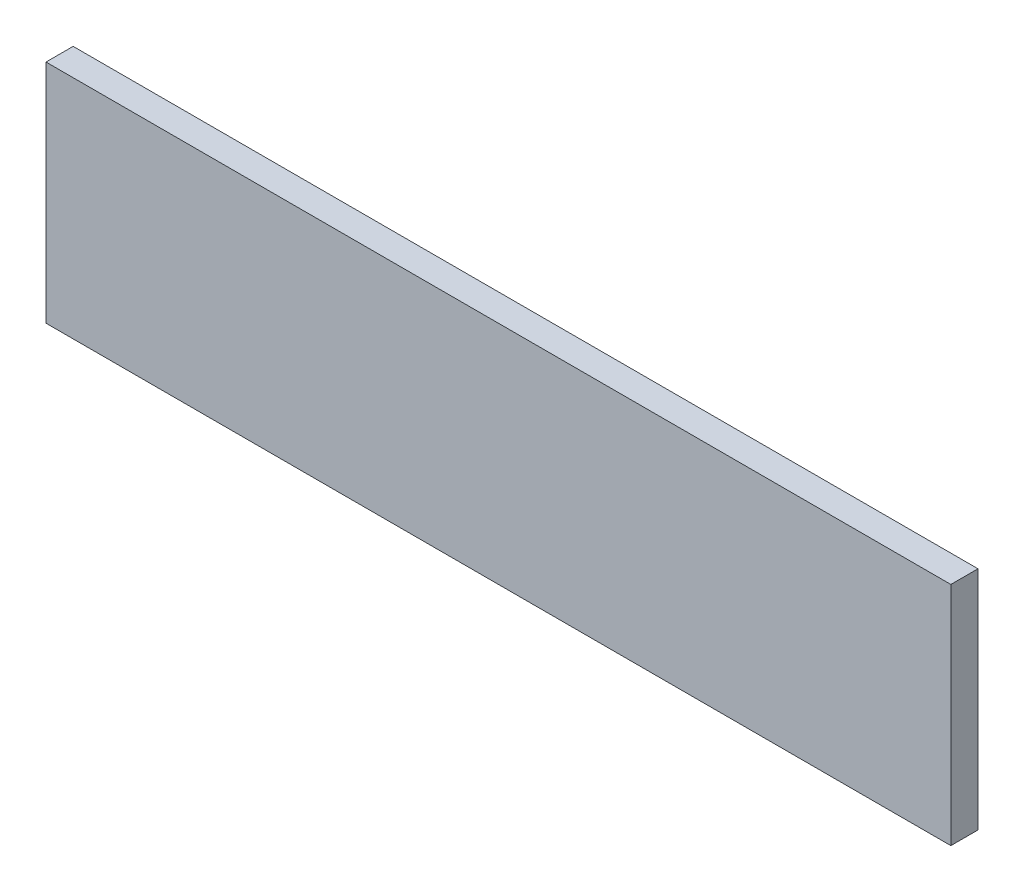
from build123d import *

# Parameters (mm, degrees)
SKETCH1_W           = 100
SKETCH1_H           = 25
BOSS_EXTRUDE1_DEPTH = 3


with BuildPart() as part:
    # Sketch1 → Boss-Extrude1 (new body)
    with BuildSketch(Plane.XY):
        with Locations((-13.358778626, 40.298982188)):
            Rectangle(SKETCH1_W, SKETCH1_H)
    extrude(amount=BOSS_EXTRUDE1_DEPTH)


solid = part.part
